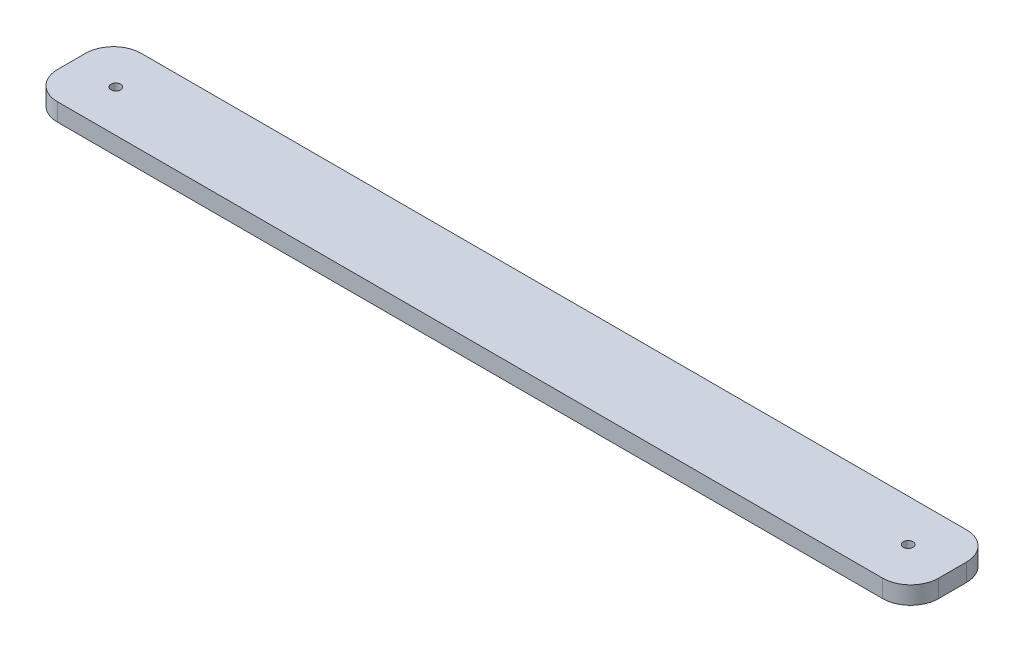
from build123d import *

# Parameters (mm, degrees)
SKETCH1_W           = 315.39
SKETCH1_H           = 30
BOSS_EXTRUDE1_DEPTH = 6.35
SKETCH4_R           = 1.75
CUT_EXTRUDE3_DEPTH  = 7.35
FILLET3_R           = 10


with BuildPart() as part:
    # Sketch1 → Boss-Extrude1 (new body)
    with BuildSketch(Plane(origin=(0, 0, 0), x_dir=(1, 0, 0), z_dir=(0, 1, 0))):
        Rectangle(SKETCH1_W, SKETCH1_H)
    extrude(amount=BOSS_EXTRUDE1_DEPTH)

    # Sketch4 → Cut-Extrude3 (cut, through all)
    with BuildSketch(Plane(origin=(0, 6.35, 0), x_dir=(1, 0, 0), z_dir=(0, 1, 0))):
        with Locations((-141.815, 0)):
            Circle(SKETCH4_R)
        with Locations((141.815, 0)):
            Circle(SKETCH4_R)
    extrude(amount=-CUT_EXTRUDE3_DEPTH, mode=Mode.SUBTRACT)

    # Fillet3
    fillet3_edges = [part.edges().sort_by_distance(p)[0] for p in [
        (157.695, 3.175, 15),
        (-157.695, 3.175, 15),
        (-157.695, 3.175, -15),
        (157.695, 3.175, -15),
    ]]
    fillet(fillet3_edges, radius=FILLET3_R)


solid = part.part
